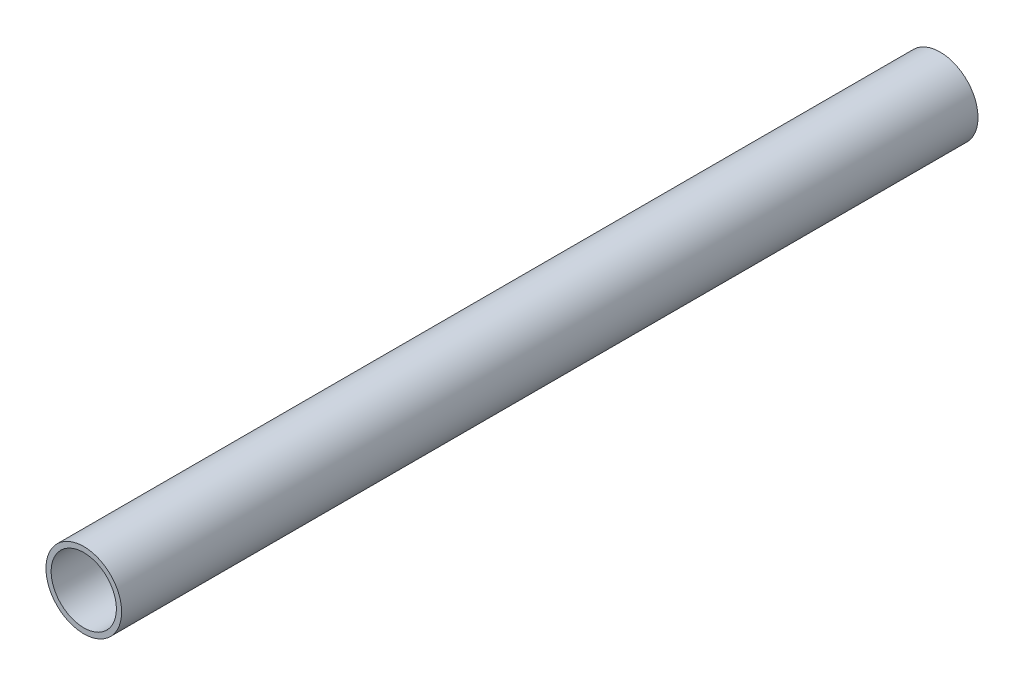
from build123d import *

# Parameters (mm, degrees)
SKETCH1_R           = 4.49
SKETCH1_R_2         = 3.87
BOSS_EXTRUDE1_DEPTH = 101.6


with BuildPart() as part:
    # Sketch1 → Boss-Extrude1 (new body)
    with BuildSketch(Plane.XY):
        Circle(SKETCH1_R)
        Circle(SKETCH1_R_2, mode=Mode.SUBTRACT)
    extrude(amount=BOSS_EXTRUDE1_DEPTH)


solid = part.part
